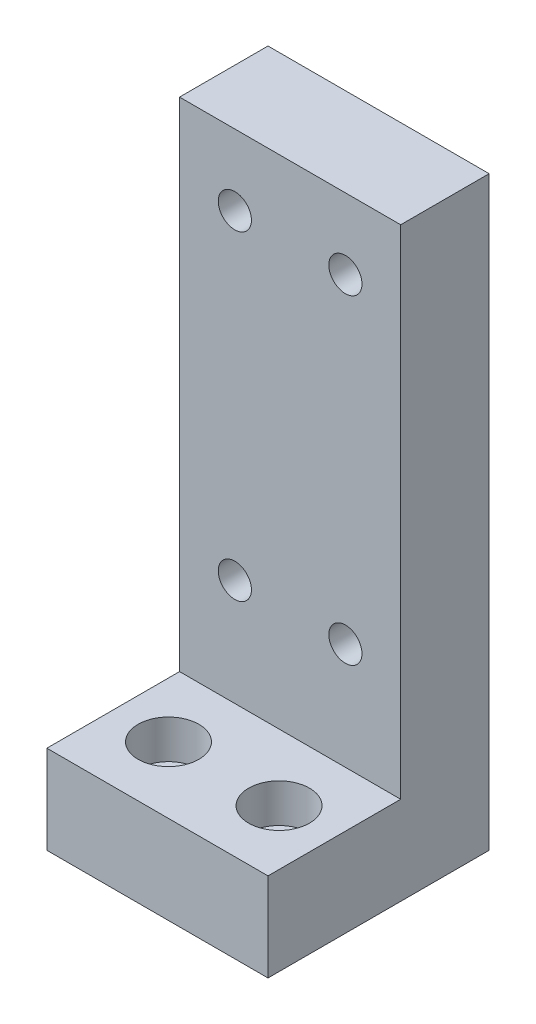
from build123d import *

# Parameters (mm, degrees)
SKETCH1_W           = 20
SKETCH1_H           = 45
BOSS_EXTRUDE1_DEPTH = 8
SKETCH2_R           = 1.5
CUT_EXTRUDE1_DEPTH  = 8
SKETCH3_R           = 2.75
CUT_EXTRUDE2_DEPTH  = 3.3
SKETCH4_W           = 20
SKETCH4_H           = 20
BOSS_EXTRUDE2_DEPTH = 8
SKETCH5_R           = 1.5
CUT_EXTRUDE3_DEPTH  = 8
SKETCH6_R           = 2.75
CUT_EXTRUDE4_DEPTH  = 3.5


with BuildPart() as part:
    # Sketch1 → Boss-Extrude1 (new body)
    with BuildSketch(Plane.XY):
        with Locations((-10, 22.5)):
            Rectangle(SKETCH1_W, SKETCH1_H)
    extrude(amount=BOSS_EXTRUDE1_DEPTH)

    # Sketch2 → Cut-Extrude1 (cut)
    with BuildSketch(Plane.XY.offset(8)):
        with Locations((-15, 38.6)):
            Circle(SKETCH2_R)
        with Locations((-5, 38.6)):
            Circle(SKETCH2_R)
        with Locations((-15, 9.65)):
            Circle(SKETCH2_R)
        with Locations((-5, 9.65)):
            Circle(SKETCH2_R)
    extrude(amount=-CUT_EXTRUDE1_DEPTH, mode=Mode.SUBTRACT)

    # Sketch3 → Cut-Extrude2 (cut)
    with BuildSketch(Plane(origin=(0, 0, 0), x_dir=(-1, 0, 0), z_dir=(0, 0, -1))):
        with Locations((5, 38.6)):
            Circle(SKETCH3_R)
        with Locations((15, 38.6)):
            Circle(SKETCH3_R)
        with Locations((5, 9.65)):
            Circle(SKETCH3_R)
        with Locations((15, 9.65)):
            Circle(SKETCH3_R)
    extrude(amount=-CUT_EXTRUDE2_DEPTH, mode=Mode.SUBTRACT)

    # Sketch4 → Boss-Extrude2 (add)
    with BuildSketch(Plane.XZ):
        with Locations((-10, 10)):
            Rectangle(SKETCH4_W, SKETCH4_H)
    extrude(amount=BOSS_EXTRUDE2_DEPTH)

    # Sketch5 → Cut-Extrude3 (cut)
    with BuildSketch(Plane(origin=(0, 0, 0), x_dir=(1, 0, 0), z_dir=(0, 1, 0))):
        with Locations((-15, -14)):
            Circle(SKETCH5_R)
        with Locations((-5, -14)):
            Circle(SKETCH5_R)
    extrude(amount=-CUT_EXTRUDE3_DEPTH, mode=Mode.SUBTRACT)

    # Sketch6 → Cut-Extrude4 (cut)
    with BuildSketch(Plane(origin=(0, 0, 0), x_dir=(1, 0, 0), z_dir=(0, 1, 0))):
        with Locations((-15, -14)):
            Circle(SKETCH6_R)
        with Locations((-5, -14)):
            Circle(SKETCH6_R)
    extrude(amount=-CUT_EXTRUDE4_DEPTH, mode=Mode.SUBTRACT)


solid = part.part
